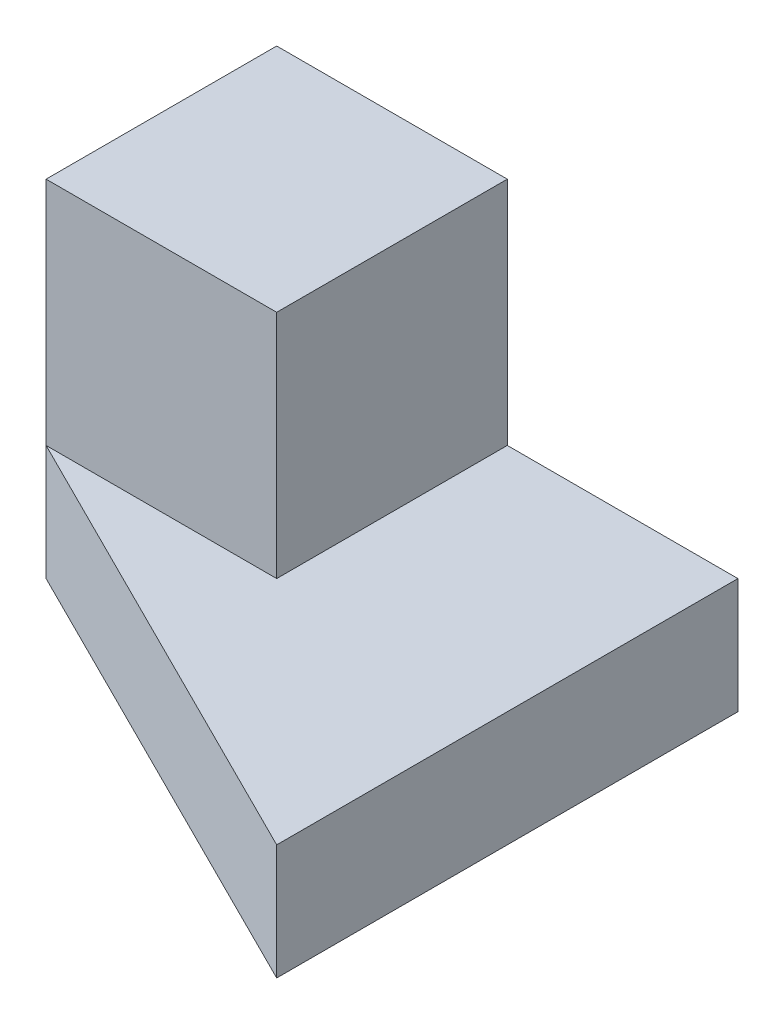
from build123d import *

# Parameters (mm, degrees)
SKETCH_1_W      = 2
SKETCH_1_H      = 2
EXTRUDE_1_DEPTH = 3
EXTRUDE_2_DEPTH = 1


with BuildPart() as part:
    # 草圖1 → 填料-伸長1 (new body)
    with BuildSketch(Plane(origin=(0, 0, 0), x_dir=(1, 0, 0), z_dir=(0, 1, 0))):
        with Locations((1, 1)):
            Rectangle(SKETCH_1_W, SKETCH_1_H)
    extrude(amount=EXTRUDE_1_DEPTH)

    # 草圖1<3> → 填料-伸長2 (add)
    with BuildSketch(Plane(origin=(0, 0, 0), x_dir=(1, 0, 0), z_dir=(0, 1, 0))):
        Polygon((2, 0), (0, 0), (4, -2), (4, 2), (2, 2), align=None)
    extrude(amount=EXTRUDE_2_DEPTH)


solid = part.part
